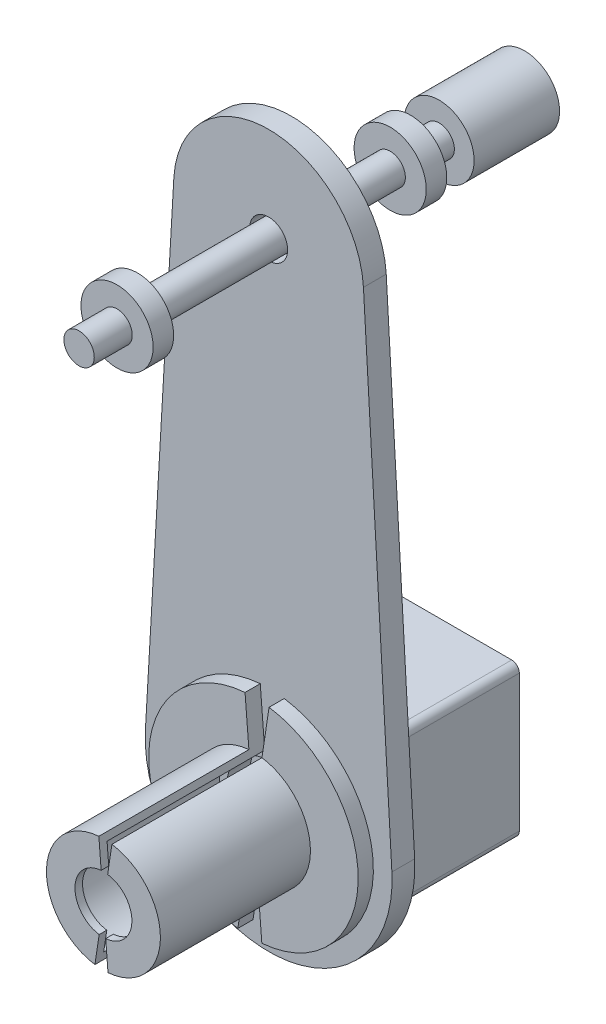
from build123d import *

# Parameters (mm, degrees)
SKETCH1_R            = 5
SKETCH1_R_2          = 11
BOSS_EXTRUDE1_DEPTH  = 6
BOSS_EXTRUDE2_DEPTH  = 40
BOSS_EXTRUDE4_DEPTH  = 4
BOSS_EXTRUDE5_DEPTH  = 43.5
SKETCH3_R            = 4
BOSS_EXTRUDE6_DEPTH  = 40.511
SKETCH4_R            = 9.5
BOSS_EXTRUDE7_DEPTH  = 5.4
SKETCH5_R            = 4
BOSS_EXTRUDE8_DEPTH  = 10
SKETCH3_2_R          = 4
BOSS_EXTRUDE9_DEPTH  = 26
SKETCH6_R            = 9.5
BOSS_EXTRUDE10_DEPTH = 5.4
SKETCH7_R            = 4
BOSS_EXTRUDE12_DEPTH = 7.5
SKETCH8_R            = 9.2
BOSS_EXTRUDE13_DEPTH = 22.5


with BuildPart() as part:
    # Sketch1 → Boss-Extrude1 (new body)
    with BuildSketch(Plane.XY):
        with BuildLine():
            Line((32.445868381, 1.875), (24.958360293, 131.442307692))
            ThreePointArc((24.958360293, 131.442307692), (0, 155), (-24.958360293, 131.442307692))
            Line((-24.958360293, 131.442307692), (-32.445868381, 1.875))
            ThreePointArc((-32.445868381, 1.875), (0, -32.5), (32.445868381, 1.875))
        make_face()
        with Locations((0, 130)):
            Circle(SKETCH1_R, mode=Mode.SUBTRACT)
        Circle(SKETCH1_R_2, mode=Mode.SUBTRACT)
    extrude(amount=BOSS_EXTRUDE1_DEPTH)

    # Sketch1_3 → Boss-Extrude2 (add)
    with BuildSketch(Plane.XY):
        with BuildLine():
            ThreePointArc((-18, 20), (-19.414213562, 19.414213562), (-20, 18))
            Line((-20, 18), (-20, -18))
            ThreePointArc((-20, -18), (-19.414213562, -19.414213562), (-18, -20))
            Line((-18, -20), (18, -20))
            ThreePointArc((18, -20), (19.414213562, -19.414213562), (20, -18))
            Line((20, -18), (20, 18))
            ThreePointArc((20, 18), (19.414213562, 19.414213562), (18, 20))
            Line((18, 20), (-18, 20))
        make_face()
    extrude(amount=-BOSS_EXTRUDE2_DEPTH)

    # Sketch2 → Boss-Extrude4 (add)
    with BuildSketch(Plane.XY.offset(6)):
        with BuildLine():
            ThreePointArc((2.210858166, -27.488234486), (27.560369933, -0.957568872), (4.113348883, 27.268503625))
            Line((4.113348883, 27.268503625), (2.237380181, 14.832199093))
            ThreePointArc((2.237380181, 14.832199093), (14.990954382, -0.520851908), (1.202555481, -14.951717638))
            Line((1.202555481, -14.951717638), (2.210858166, -27.488234486))
        make_face()
        with BuildLine():
            Line((-1.202555481, 14.951717638), (-2.210858166, 27.488234486))
            ThreePointArc((-2.210858166, 27.488234486), (-27.560369933, 0.957568872), (-4.113348883, -27.268503625))
            Line((-4.113348883, -27.268503625), (-2.237380181, -14.832199093))
            ThreePointArc((-2.237380181, -14.832199093), (-14.990954382, 0.520851908), (-1.202555481, 14.951717638))
        make_face()
    extrude(amount=BOSS_EXTRUDE4_DEPTH)

    # Sketch2_3 → Boss-Extrude5 (add)
    with BuildSketch(Plane.XY.offset(6)):
        with BuildLine():
            Line((2.237380181, 14.832199093), (1.11869009, 7.416099546))
            ThreePointArc((1.11869009, 7.416099546), (7.495477191, -0.260425954), (0.60127774, -7.475858819))
            Line((0.60127774, -7.475858819), (1.202555481, -14.951717638))
            ThreePointArc((1.202555481, -14.951717638), (14.990954382, -0.520851908), (2.237380181, 14.832199093))
        make_face()
        with BuildLine():
            ThreePointArc((-1.202555481, 14.951717638), (-14.990954382, 0.520851908), (-2.237380181, -14.832199093))
            Line((-2.237380181, -14.832199093), (-1.11869009, -7.416099546))
            ThreePointArc((-1.11869009, -7.416099546), (-7.495477191, 0.260425954), (-0.60127774, 7.475858819))
            Line((-0.60127774, 7.475858819), (-1.202555481, 14.951717638))
        make_face()
    extrude(amount=BOSS_EXTRUDE5_DEPTH)

    # Sketch9 → Cut-Revolve1 (revolve, cut)
    with BuildSketch(Plane.ZY):
        Polygon((6, -7.475858819), (6, -10.964592934), (6, -12.951717638), (47.5, -12.951717638), (47.5, -7.475858819), align=None)
    revolve(axis=Axis((0, 0, 3.424764537), (0, 0, 1)), mode=Mode.SUBTRACT)


with BuildPart() as body_2:
    # Sketch3 → Boss-Extrude6 (new body)
    with BuildSketch(Plane(origin=(0, 0, 0), x_dir=(-1, 0, 0), z_dir=(0, 0, -1))):
        with Locations((0, 130)):
            Circle(SKETCH3_R)
    extrude(amount=-BOSS_EXTRUDE6_DEPTH)

    # Sketch4 → Boss-Extrude7 (add)
    with BuildSketch(Plane.XY.offset(40.511)):
        with Locations((0, 130)):
            Circle(SKETCH4_R)
    extrude(amount=BOSS_EXTRUDE7_DEPTH)

    # Sketch5 → Boss-Extrude8 (add)
    with BuildSketch(Plane.XY.offset(45.911)):
        with Locations((0, 130)):
            Circle(SKETCH5_R)
    extrude(amount=BOSS_EXTRUDE8_DEPTH)

    # Sketch3_2 → Boss-Extrude9 (add)
    with BuildSketch(Plane(origin=(0, 0, 0), x_dir=(-1, 0, 0), z_dir=(0, 0, -1))):
        with Locations((0, 130)):
            Circle(SKETCH3_2_R)
    extrude(amount=BOSS_EXTRUDE9_DEPTH)

    # Sketch6 → Boss-Extrude10 (add)
    with BuildSketch(Plane(origin=(0, 0, -26), x_dir=(-1, 0, 0), z_dir=(0, 0, -1))):
        with Locations((0, 130)):
            Circle(SKETCH6_R)
    extrude(amount=BOSS_EXTRUDE10_DEPTH)

    # Sketch7 → Boss-Extrude12 (add)
    with BuildSketch(Plane(origin=(0, 0, -31.4), x_dir=(-1, 0, 0), z_dir=(0, 0, -1))):
        with Locations((0, 130)):
            Circle(SKETCH7_R)
    extrude(amount=BOSS_EXTRUDE12_DEPTH)

    # Sketch8 → Boss-Extrude13 (add)
    with BuildSketch(Plane(origin=(0, 0, -38.9), x_dir=(-1, 0, 0), z_dir=(0, 0, -1))):
        with Locations((0, 130)):
            Circle(SKETCH8_R)
    extrude(amount=BOSS_EXTRUDE13_DEPTH)


solid = Compound([part.part, body_2.part])
